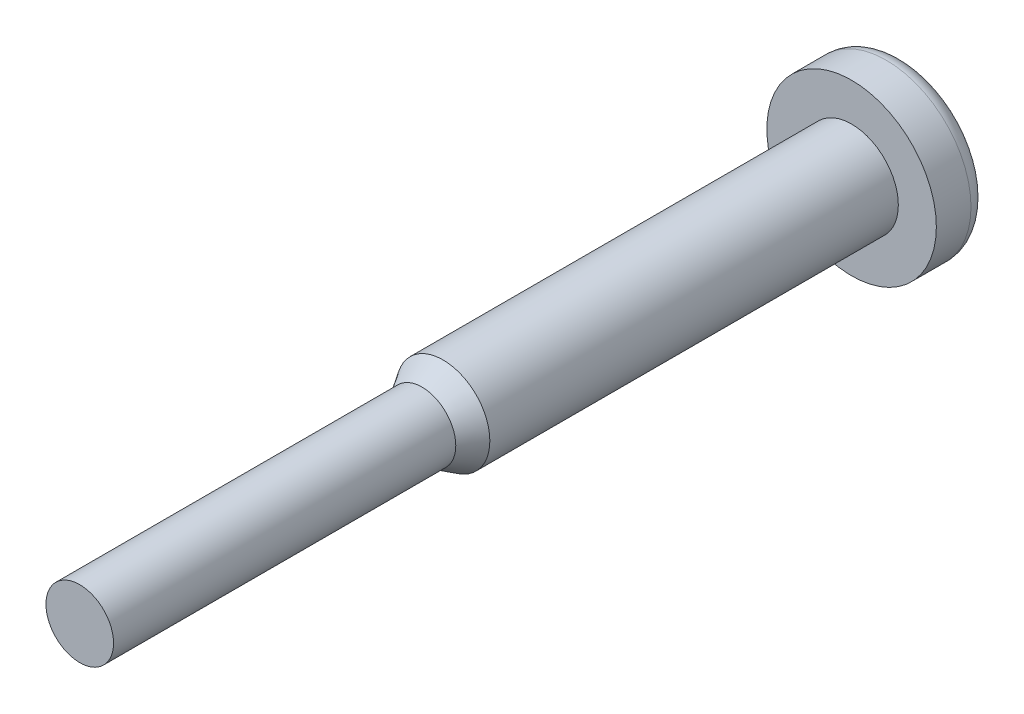
from build123d import *


with BuildPart() as part:
    # Esquisse1 → Révolution1 (revolve)
    with BuildSketch(Plane(origin=(0, 0, 0), x_dir=(0, 0, -1), z_dir=(1, 0, 0))):
        with BuildLine():
            Line((97.44, 0), (97.44, 8.03))
            ThreePointArc((97.44, 8.03), (96.854213562, 9.444213562), (95.44, 10.03))
            Line((95.44, 10.03), (91.34, 10.03))
            Line((91.34, 10.03), (91.34, 5.53))
            Line((91.34, 5.53), (43, 5.53))
            Line((43, 5.53), (40.5, 4))
            Line((40.5, 4), (0, 4))
            Line((0, 4), (0, 0))
            Line((0, 0), (97.44, 0))
        make_face()
    revolve(axis=Axis((0, 0, 0), (0, 0, -1)))


solid = part.part
